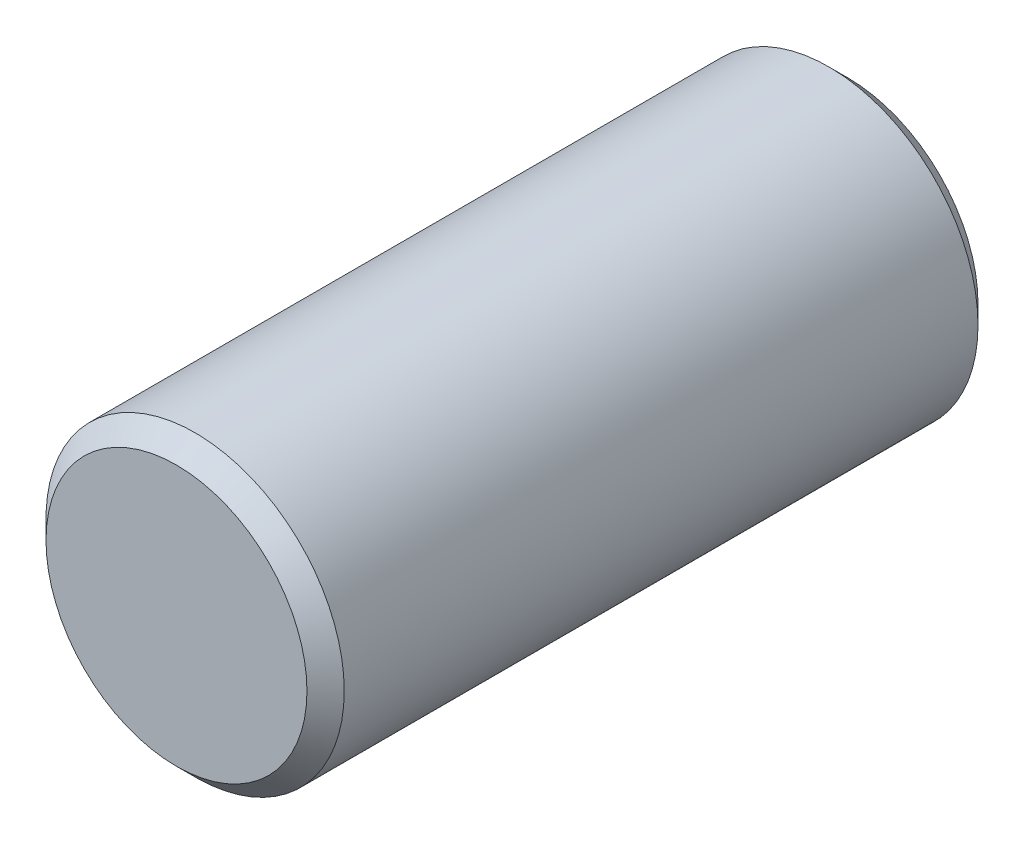
from build123d import *

# Parameters (mm, degrees)
BOSS_EXTRUDE1_DEPTH      = 9
BOSS_EXTRUDE1_DEPTH_BACK = 9
SKETCH1_R                = 4
CHAMFER1_SIZE            = 0.5


with BuildPart() as part:
    # Sketch1 → Boss-Extrude1 (new, two sides: drawn at the far end of the back side and taken through both)
    with BuildSketch(Plane.XY.offset(-BOSS_EXTRUDE1_DEPTH_BACK)):
        Circle(SKETCH1_R)
    extrude(amount=BOSS_EXTRUDE1_DEPTH + BOSS_EXTRUDE1_DEPTH_BACK)

    # Chamfer1
    chamfer1_edges = [part.edges().sort_by_distance(p)[0] for p in [
        (-4, 0, -9),
        (-4, 0, 9),
    ]]
    chamfer(chamfer1_edges, length=CHAMFER1_SIZE)


solid = part.part
